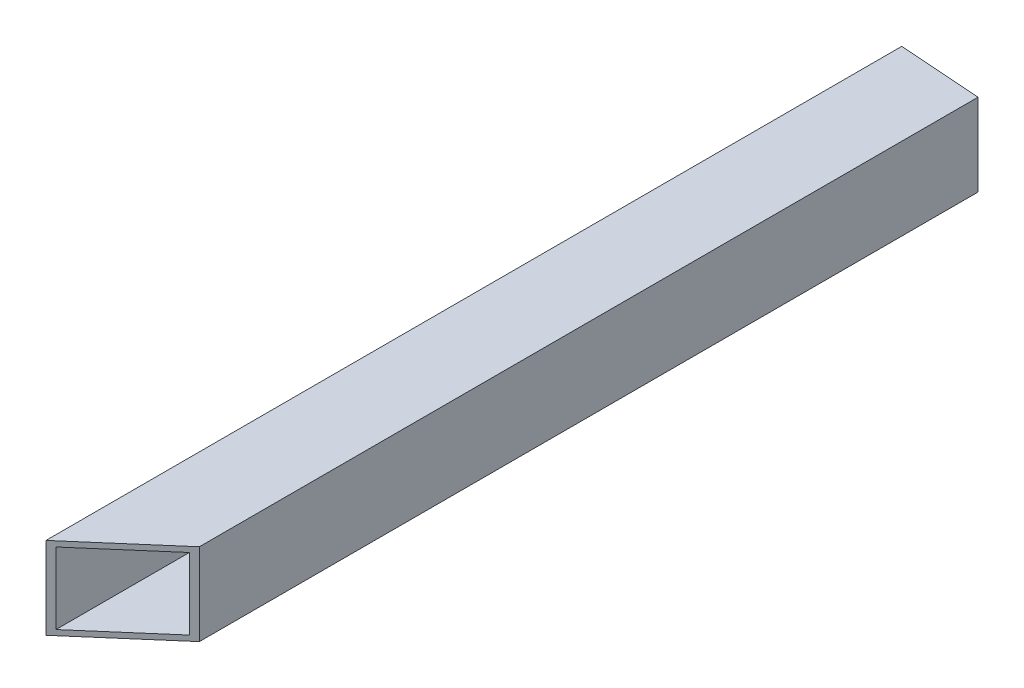
from build123d import *

# Parameters (mm, degrees)
SKETCH1_W           = 25.4
SKETCH1_H           = 25.4
SKETCH1_W_2         = 22.098
SKETCH1_H_2         = 22.098
BOSS_EXTRUDE1_DEPTH = 252.579
SKETCH5_W           = 25.4
SKETCH5_H           = 25.4
SKETCH5_W_2         = 22.098
SKETCH5_H_2         = 22.098
BOSS_EXTRUDE2_DEPTH = 12.7
CUT_EXTRUDE1_DEPTH  = 36.4
SKETCH7_W           = 25.4
SKETCH7_H           = 25.4
SKETCH7_W_2         = 22.098
SKETCH7_H_2         = 22.098
BOSS_EXTRUDE3_DEPTH = 25.4
CUT_EXTRUDE2_DEPTH  = 165.021579309


with BuildPart() as part:
    # Sketch1 → Boss-Extrude1 (new body)
    with BuildSketch(Plane.XY):
        Rectangle(SKETCH1_W, SKETCH1_H)
        Rectangle(SKETCH1_W_2, SKETCH1_H_2, mode=Mode.SUBTRACT)
    extrude(amount=BOSS_EXTRUDE1_DEPTH)

    # Sketch5 → Boss-Extrude2 (add)
    with BuildSketch(Plane.XY.offset(252.579)):
        Rectangle(SKETCH5_W, SKETCH5_H)
        Rectangle(SKETCH5_W_2, SKETCH5_H_2, mode=Mode.SUBTRACT)
    extrude(amount=BOSS_EXTRUDE2_DEPTH)

    # Sketch6 → Cut-Extrude1 (cut, through all)
    with BuildSketch(Plane(origin=(0, -22.7, 252.579), x_dir=(-0.142456183, 0, 0.989801109), z_dir=(0, -1, 0))):
        Polygon((-25.049344305, -21.702249197), (26.869925532, 23.279564235), (45.864950848, -41.551460554), align=None)
    extrude(amount=-CUT_EXTRUDE1_DEPTH, mode=Mode.SUBTRACT)

    # Sketch7 → Boss-Extrude3 (add)
    with BuildSketch(Plane(origin=(0, 0, 0), x_dir=(-1, 0, 0), z_dir=(0, 0, -1))):
        Rectangle(SKETCH7_W, SKETCH7_H)
        Rectangle(SKETCH7_W_2, SKETCH7_H_2, mode=Mode.SUBTRACT)
    extrude(amount=BOSS_EXTRUDE3_DEPTH)

    # Sketch8 → Cut-Extrude2 (cut, through all)
    with BuildSketch(Plane(origin=(602.971957407, 151.321579309, -52.668394102), x_dir=(0.142456183, 0, -0.989801109), z_dir=(0, -1, 0))):
        Polygon((-136.208901871, -563.906106683), (-139.847734949, -614.732641149), (-41.725602435, -599.280432209), align=None)
    extrude(amount=CUT_EXTRUDE2_DEPTH, mode=Mode.SUBTRACT)


solid = part.part
